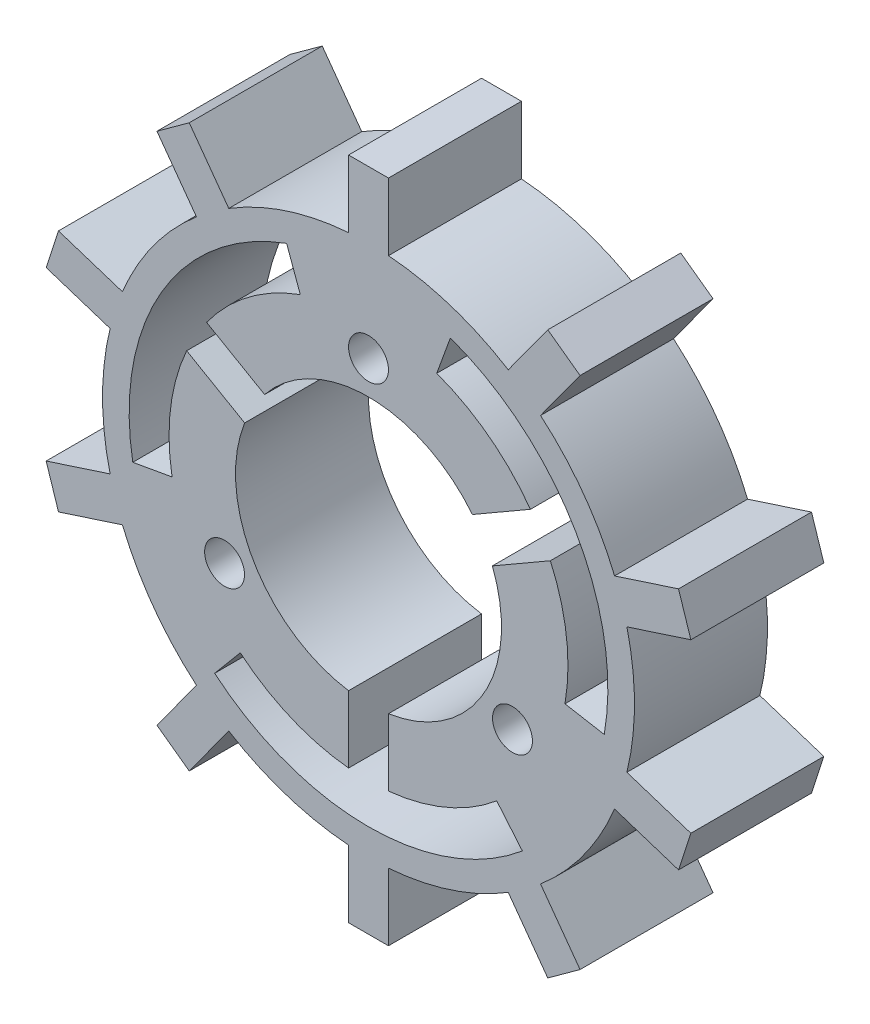
from build123d import *

# Parameters (mm, degrees)
SKETCH_1_R          = 1.5
EXTRUDE_1_DEPTH     = 10
CUT_EXTRUDE_2_DEPTH = 10


with BuildPart() as part:
    # 草图1 → 凸台-拉伸1 (new body)
    with BuildSketch(Plane.XY):
        with BuildLine():
            Line((1.5, 19.943670675), (1.5, 25))
            Line((1.5, 25), (-1.5, 25))
            Line((-1.5, 25), (-1.5, 19.943670675))
            ThreePointArc((-1.5, 19.943670675), (-6.180339888, 19.021130326), (-10.509070008, 17.016446385))
            Line((-10.509070008, 17.016446385), (-13.481105816, 21.107102738))
            Line((-13.481105816, 21.107102738), (-15.908156799, 19.343746981))
            Line((-15.908156799, 19.343746981), (-12.936120991, 15.253090628))
            ThreePointArc((-12.936120991, 15.253090628), (-16.180339887, 11.755705046), (-18.504032463, 7.589517943))
            Line((-18.504032463, 7.589517943), (-23.312887416, 9.152009634))
            Line((-23.312887416, 9.152009634), (-24.239938399, 6.298840085))
            Line((-24.239938399, 6.298840085), (-19.431083446, 4.736348394))
            ThreePointArc((-19.431083446, 4.736348394), (-20, 0), (-19.431083446, -4.736348394))
            Line((-19.431083446, -4.736348394), (-24.239938399, -6.298840085))
            Line((-24.239938399, -6.298840085), (-23.312887416, -9.152009634))
            Line((-23.312887416, -9.152009634), (-18.504032463, -7.589517943))
            ThreePointArc((-18.504032463, -7.589517943), (-16.180339887, -11.755705046), (-12.936120991, -15.253090628))
            Line((-12.936120991, -15.253090628), (-15.908156799, -19.343746981))
            Line((-15.908156799, -19.343746981), (-13.481105816, -21.107102738))
            Line((-13.481105816, -21.107102738), (-10.509070008, -17.016446385))
            ThreePointArc((-10.509070008, -17.016446385), (-6.180339887, -19.021130326), (-1.5, -19.943670675))
            Line((-1.5, -19.943670675), (-1.5, -25))
            Line((-1.5, -25), (1.5, -25))
            Line((1.5, -25), (1.5, -19.943670675))
            ThreePointArc((1.5, -19.943670675), (6.180339888, -19.021130326), (10.509070008, -17.016446385))
            Line((10.509070008, -17.016446385), (13.481105816, -21.107102738))
            Line((13.481105816, -21.107102738), (15.908156799, -19.343746981))
            Line((15.908156799, -19.343746981), (12.936120991, -15.253090628))
            ThreePointArc((12.936120991, -15.253090628), (16.180339887, -11.755705046), (18.504032463, -7.589517943))
            Line((18.504032463, -7.589517943), (23.312887416, -9.152009634))
            Line((23.312887416, -9.152009634), (24.239938399, -6.298840085))
            Line((24.239938399, -6.298840085), (19.431083446, -4.736348394))
            ThreePointArc((19.431083446, -4.736348394), (20, 0), (19.431083446, 4.736348394))
            Line((19.431083446, 4.736348394), (24.239938399, 6.298840085))
            Line((24.239938399, 6.298840085), (23.312887416, 9.152009634))
            Line((23.312887416, 9.152009634), (18.504032463, 7.589517943))
            ThreePointArc((18.504032463, 7.589517943), (16.180339887, 11.755705046), (12.936120991, 15.253090628))
            Line((12.936120991, 15.253090628), (15.908156799, 19.343746981))
            Line((15.908156799, 19.343746981), (13.481105816, 21.107102738))
            Line((13.481105816, 21.107102738), (10.509070008, 17.016446385))
            ThreePointArc((10.509070008, 17.016446385), (6.180339887, 19.021130326), (1.5, 19.943670675))
        make_face()
        with Locations((0, 12.5)):
            Circle(SKETCH_1_R, mode=Mode.SUBTRACT)
        with Locations((10.825317547, -6.25)):
            Circle(SKETCH_1_R, mode=Mode.SUBTRACT)
        with Locations((-10.825317547, -6.25)):
            Circle(SKETCH_1_R, mode=Mode.SUBTRACT)
    extrude(amount=EXTRUDE_1_DEPTH)

    # 草图2 → 切除-拉伸2 (cut)
    with BuildSketch(Plane.XY):
        with BuildLine():
            Line((-9.312271895, 3.644391878), (-13.675265955, 6.163367673))
            ThreePointArc((-13.675265955, 6.163367673), (-14.883992786, 1.861923398), (-14.772116295, -2.604722665))
            Line((-14.772116295, -2.604722665), (-17.726539554, -3.125667198))
            ThreePointArc((-17.726539554, -3.125667198), (-15.588457268, 9), (-6.15636258, 16.914467174))
            Line((-6.15636258, 16.914467174), (-5.13030215, 14.095389312))
            ThreePointArc((-5.13030215, 14.095389312), (-9.054469356, 11.958954164), (-12.175265955, 8.761443884))
            Line((-12.175265955, 8.761443884), (-7.812271895, 6.242468089))
            ThreePointArc((-7.812271895, 6.242468089), (0, 10), (7.812271895, 6.242468089))
            Line((7.812271895, 6.242468089), (12.175265955, 8.761443884))
            ThreePointArc((12.175265955, 8.761443884), (9.054469356, 11.958954164), (5.13030215, 14.095389312))
            Line((5.13030215, 14.095389312), (6.15636258, 16.914467174))
            ThreePointArc((6.15636258, 16.914467174), (15.588457268, 9), (17.726539554, -3.125667198))
            Line((17.726539554, -3.125667198), (14.772116295, -2.604722665))
            ThreePointArc((14.772116295, -2.604722665), (14.883992786, 1.861923398), (13.675265955, 6.163367673))
            Line((13.675265955, 6.163367673), (9.312271895, 3.644391878))
            ThreePointArc((9.312271895, 3.644391878), (8.660254038, -5), (1.5, -9.886859967))
            Line((1.5, -9.886859967), (1.5, -14.924811557))
            ThreePointArc((1.5, -14.924811557), (5.829523431, -13.820877562), (9.641814145, -11.490666647))
            Line((9.641814145, -11.490666647), (11.570176974, -13.788799976))
            ThreePointArc((11.570176974, -13.788799976), (0, -18), (-11.570176974, -13.788799976))
            Line((-11.570176974, -13.788799976), (-9.641814145, -11.490666647))
            ThreePointArc((-9.641814145, -11.490666647), (-5.829523431, -13.820877562), (-1.5, -14.924811557))
            Line((-1.5, -14.924811557), (-1.5, -9.886859967))
            ThreePointArc((-1.5, -9.886859967), (-8.660254038, -5), (-9.312271895, 3.644391878))
        make_face()
    extrude(amount=CUT_EXTRUDE_2_DEPTH, mode=Mode.SUBTRACT)


solid = part.part
